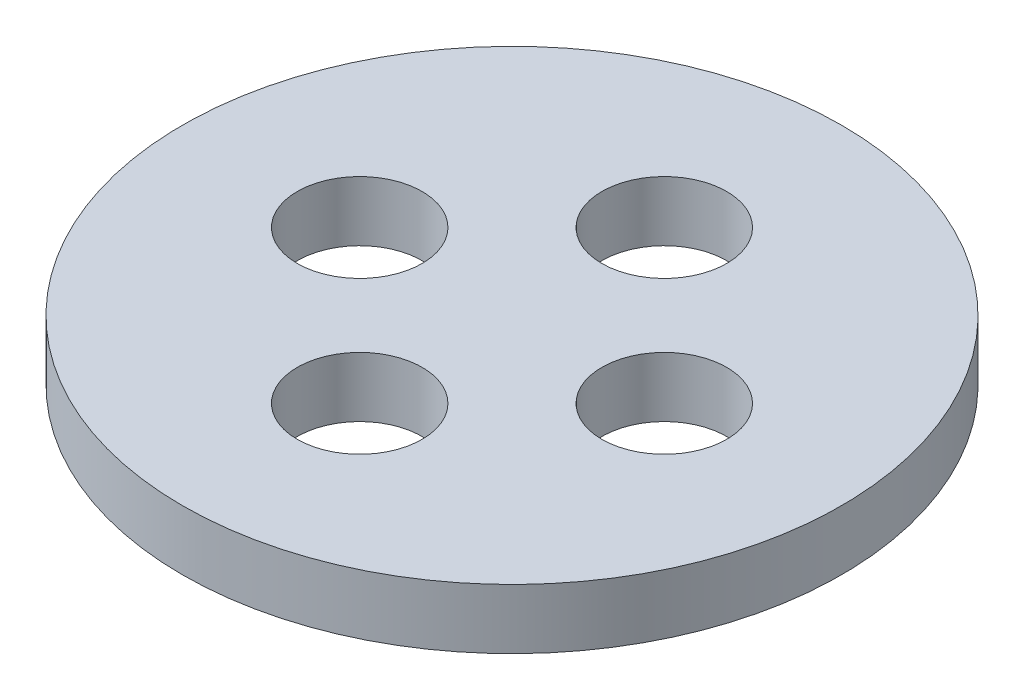
from build123d import *

# Parameters (mm, degrees)
SKETCH_1_R      = 66
SKETCH_1_R_2    = 12.5
EXTRUDE_1_DEPTH = 12


with BuildPart() as part:
    # ｽｹｯﾁ1 → ﾎﾞｽ - 押し出し1 (new body)
    with BuildSketch(Plane(origin=(0, 0, 0), x_dir=(1, 0, 0), z_dir=(0, 1, 0))):
        with Locations(Location((0, 0, 0), (0, 0, 270))):  # turned: the seam where the file's is
            Circle(SKETCH_1_R)
        with Locations(Location((0, 30.5, 0), (0, 0, 270))):  # turned: the seam where the file's is
            Circle(SKETCH_1_R_2, mode=Mode.SUBTRACT)
        with Locations(Location((30.5, 0, 0), (0, 0, 270))):  # turned: the seam where the file's is
            Circle(SKETCH_1_R_2, mode=Mode.SUBTRACT)
        with Locations(Location((0, -30.5, 0), (0, 0, 270))):  # turned: the seam where the file's is
            Circle(SKETCH_1_R_2, mode=Mode.SUBTRACT)
        with Locations(Location((-30.5, 0, 0), (0, 0, 270))):  # turned: the seam where the file's is
            Circle(SKETCH_1_R_2, mode=Mode.SUBTRACT)
    extrude(amount=EXTRUDE_1_DEPTH)


solid = part.part
